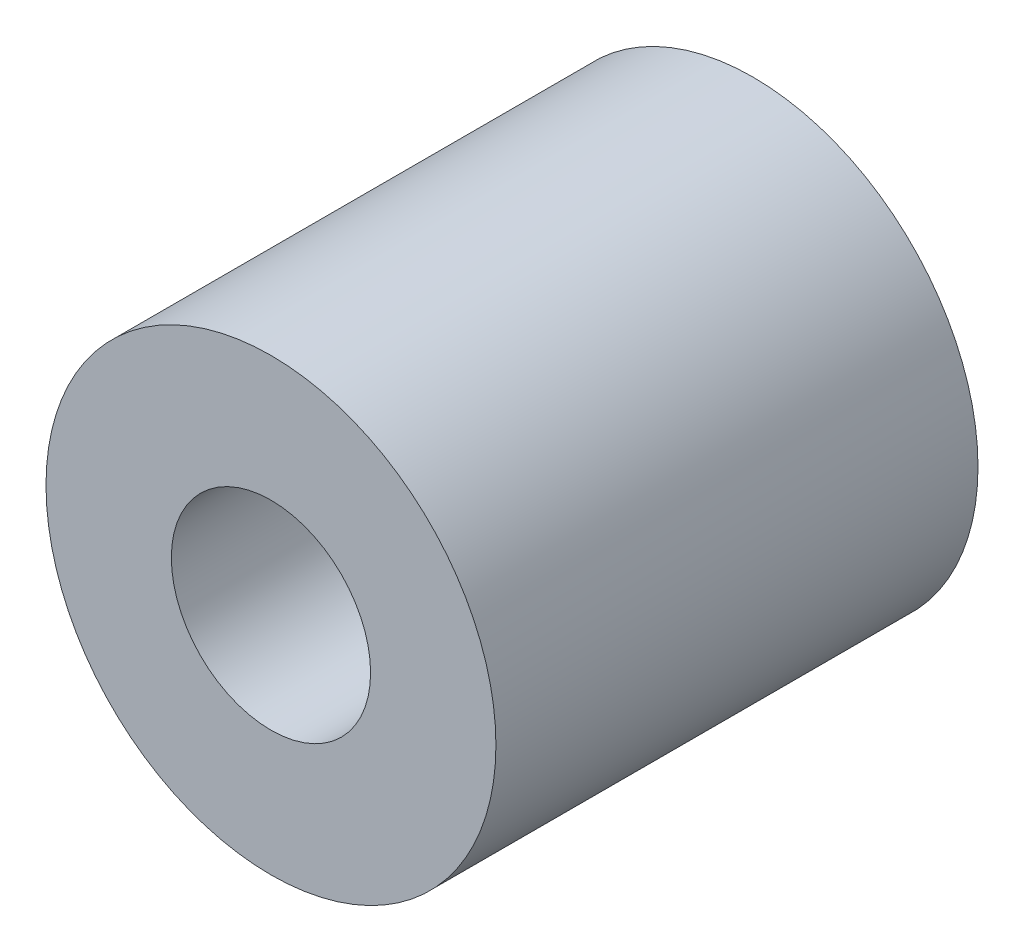
from build123d import *

# Parameters (mm, degrees)
SKETCH1_R           = 8.89
BOSS_EXTRUDE2_DEPTH = 19.05
SKETCH2_R           = 3.937
CUT_EXTRUDE1_DEPTH  = 19.558


with BuildPart() as part:
    # Sketch1 → Boss-Extrude2 (new body)
    with BuildSketch(Plane.XY):
        Circle(SKETCH1_R)
    extrude(amount=BOSS_EXTRUDE2_DEPTH)

    # Sketch2 → Cut-Extrude1 (cut)
    with BuildSketch(Plane.XY.offset(19.05)):
        Circle(SKETCH2_R)
    extrude(amount=-CUT_EXTRUDE1_DEPTH, mode=Mode.SUBTRACT)


solid = part.part
